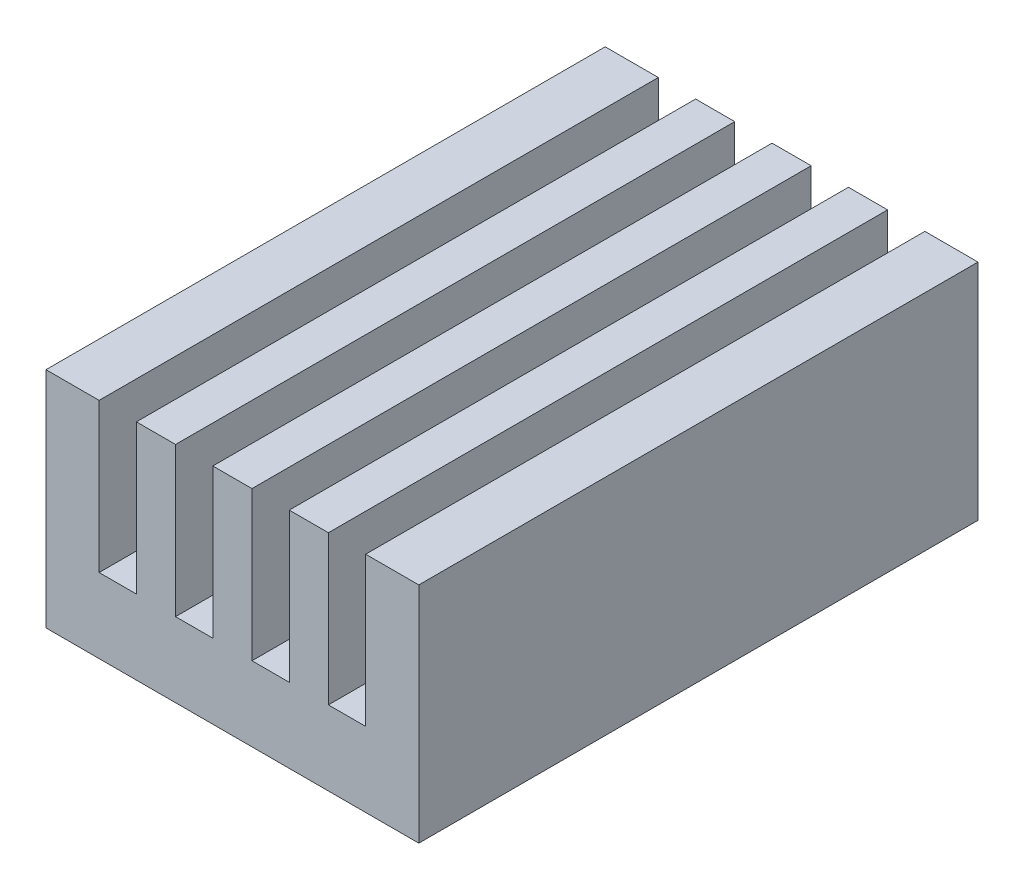
from build123d import *

# Parameters (mm, degrees)
BOSS_EXTRUDE1_DEPTH = 15


with BuildPart() as part:
    # Sketch1 → Boss-Extrude1 (new body)
    with BuildSketch(Plane.XY):
        Polygon((-3.575, 6), (-5, 6), (-5, 0), (5, 0), (5, 6), (3.575, 6), (3.575, 2), (2.575, 2), (2.575, 6), (1.525, 6), (1.525, 2), (0.525, 2), (0.525, 6), (-0.525, 6), (-0.525, 2), (-1.525, 2), (-1.525, 6), (-2.575, 6), (-2.575, 2), (-3.575, 2), align=None)
    extrude(amount=BOSS_EXTRUDE1_DEPTH)


solid = part.part
